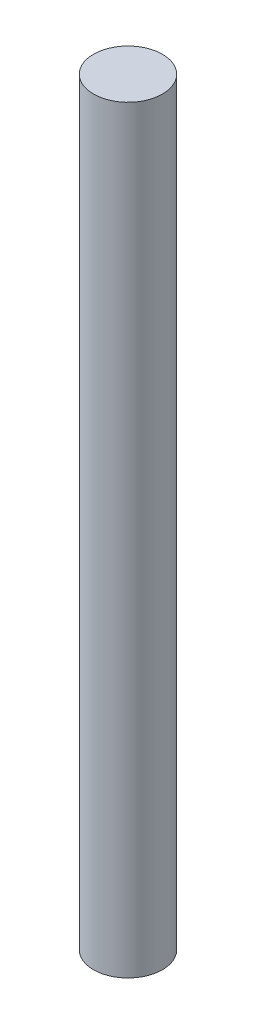
from build123d import *

# Parameters (mm, degrees)
SKETCH1_R           = 12.7
BOSS_EXTRUDE1_DEPTH = 139.7


with BuildPart() as part:
    # Sketch1 → Boss-Extrude1 (new body, symmetric)
    with BuildSketch(Plane(origin=(0, 0, 0), x_dir=(1, 0, 0), z_dir=(0, 1, 0))):
        Circle(SKETCH1_R)
    extrude(amount=BOSS_EXTRUDE1_DEPTH, both=True)


solid = part.part
